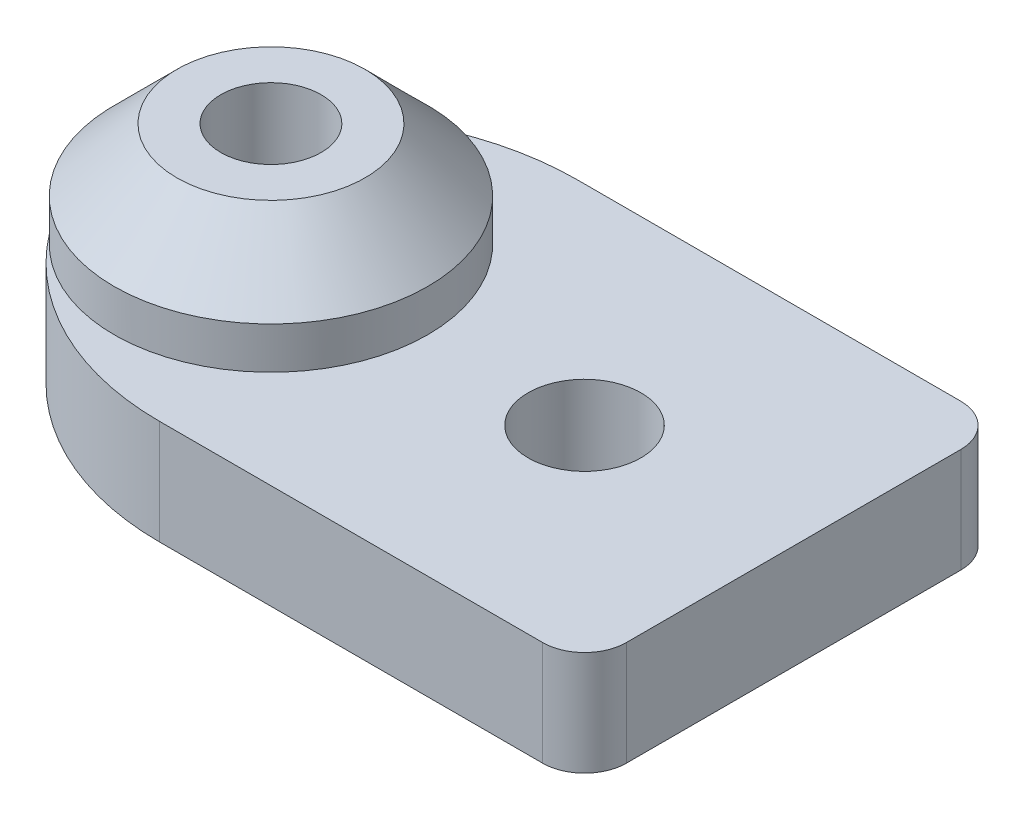
from build123d import *

# Parameters (mm, degrees)
SKETCH1_R           = 2.7
SKETCH1_R_2         = 2.4
BOSS_EXTRUDE1_DEPTH = 5
SKETCH2_R           = 7.5
SKETCH2_R_2         = 2.4
BOSS_EXTRUDE2_DEPTH = 5
CHAMFER1_SIZE       = 3
FILLET1_R           = 2


with BuildPart() as part:
    # Sketch1 → Boss-Extrude1 (new body)
    with BuildSketch(Plane(origin=(0, 0, 0), x_dir=(1, 0, 0), z_dir=(0, 1, 0))):
        with BuildLine():
            Line((4.667976007, 0), (25, 0))
            Line((25, 0), (25, 20))
            Line((25, 20), (4.667976007, 20))
            ThreePointArc((4.667976007, 20), (-1.520553083, 18.447162124), (-6.242835244, 14.156562054))
            ThreePointArc((-6.242835244, 14.156562054), (-7.5, 10), (-6.242835244, 5.843437946))
            ThreePointArc((-6.242835244, 5.843437946), (-1.520553083, 1.552837876), (4.667976007, 0))
        make_face()
        with Locations((15, 10)):
            Circle(SKETCH1_R, mode=Mode.SUBTRACT)
        with Locations((0, 10)):
            Circle(SKETCH1_R_2, mode=Mode.SUBTRACT)
    extrude(amount=BOSS_EXTRUDE1_DEPTH)

    # Sketch2 → Boss-Extrude2 (add)
    with BuildSketch(Plane(origin=(0, 5, 0), x_dir=(1, 0, 0), z_dir=(0, 1, 0))):
        with Locations((0, 10)):
            Circle(SKETCH2_R)
        with Locations((0, 10)):
            Circle(SKETCH2_R_2, mode=Mode.SUBTRACT)
    extrude(amount=BOSS_EXTRUDE2_DEPTH)

    # Chamfer1
    chamfer1_edges = [part.edges().sort_by_distance(p)[0] for p in [
        (-7.5, 10, -10),
    ]]
    chamfer(chamfer1_edges, length=CHAMFER1_SIZE)

    # Fillet1
    fillet1_edges = [part.edges().sort_by_distance(p)[0] for p in [
        (25, 2.5, -20),
        (25, 2.5, 0),
    ]]
    fillet(fillet1_edges, radius=FILLET1_R)


solid = part.part
